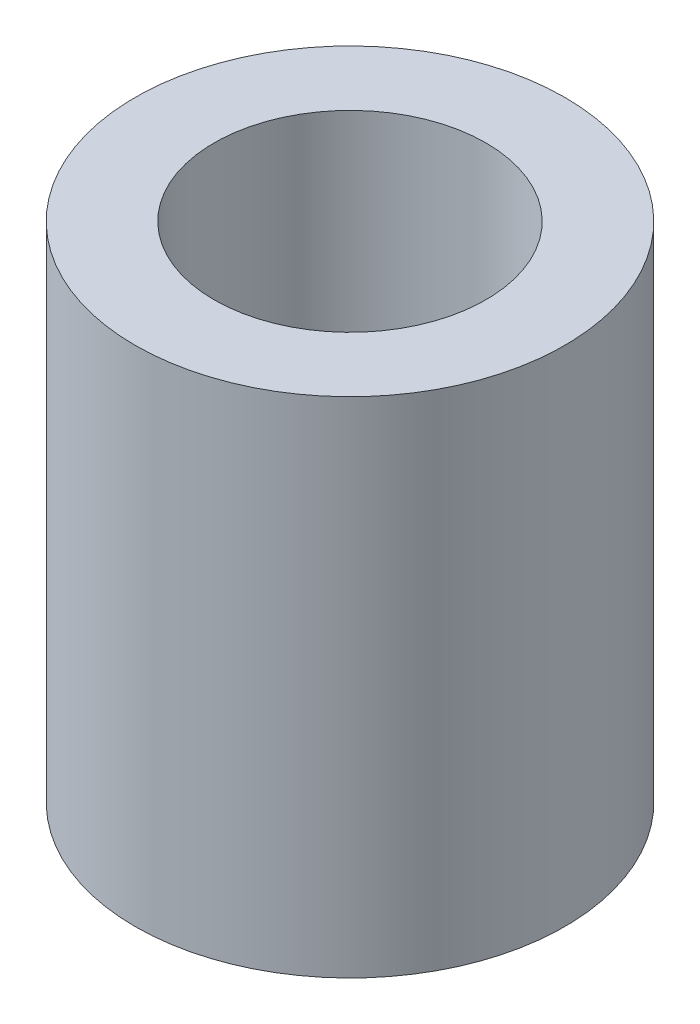
from build123d import *

# Parameters (mm, degrees)
SKETCH2_R           = 3.2
SKETCH2_R_2         = 2.025
BOSS_EXTRUDE1_DEPTH = 7.5


with BuildPart() as part:
    # Sketch2 → Boss-Extrude1 (new body)
    with BuildSketch(Plane(origin=(0, 0, 0), x_dir=(1, 0, 0), z_dir=(0, 1, 0))):
        Circle(SKETCH2_R)
        Circle(SKETCH2_R_2, mode=Mode.SUBTRACT)
    extrude(amount=BOSS_EXTRUDE1_DEPTH)


solid = part.part
